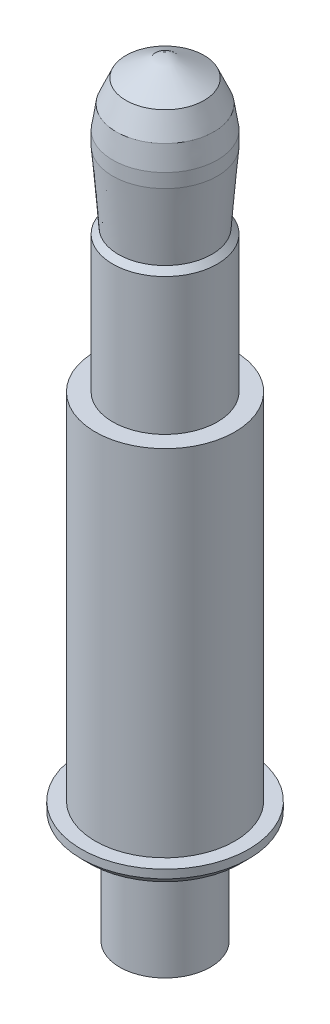
from build123d import *

# Parameters (mm, degrees)
CHAMFER1_SIZE = 0.06


with BuildPart() as part:
    # Sketch1 → Revolve1 (revolve)
    with BuildSketch(Plane(origin=(0, 0, 0), x_dir=(-1, 0, 0), z_dir=(0, 0, -1))):
        Polygon((0, 5.52), (-0.28, 5.358341925), (-0.35, 5.198341925), (-0.375, 5.035841925), (-0.375, 4.935841925), (-0.335, 4.43), (-0.375, 4.39), (-0.375, 3.41), (-0.5, 3.41), (-0.5, 0.87), (-0.6, 0.87), (-0.6, 0.75), (-0.325, 0.75), (-0.325, 0), (0, -0.022), align=None)
    revolve(axis=Axis((0, -1000, 0), (0, 1, 0)))

    # Chamfer1
    chamfer1_edges = [part.edges().sort_by_distance(p)[0] for p in [
        (-0.6, 0.75, 0),
    ]]
    chamfer(chamfer1_edges, length=CHAMFER1_SIZE)


solid = part.part
